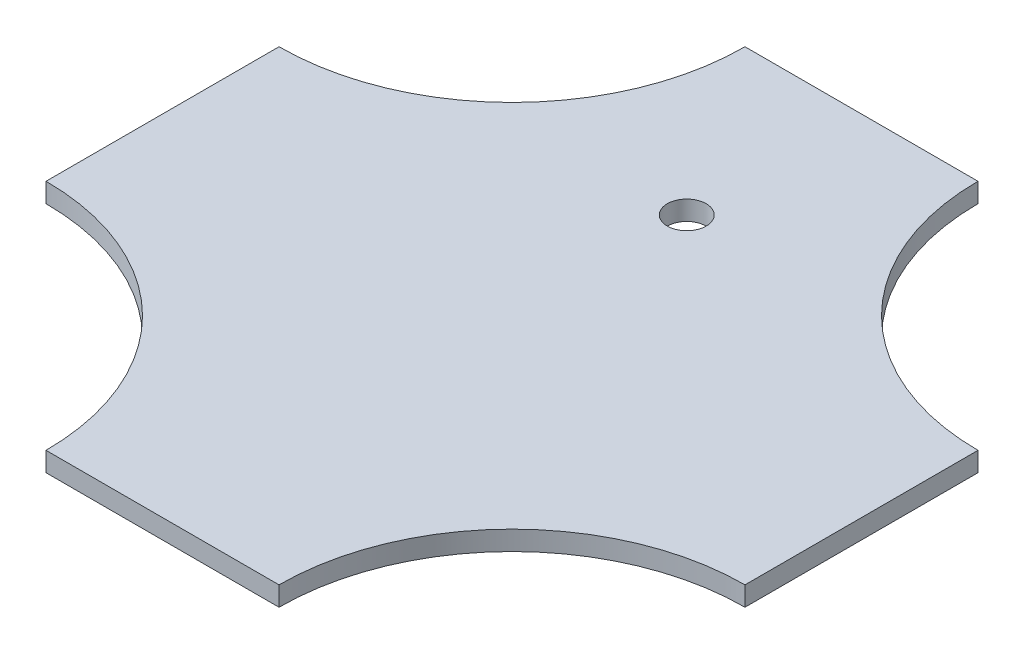
from build123d import *

# Parameters (mm, degrees)
BOSS_EXTRUDE1_DEPTH = 10
SKETCH2_R           = 10
CUT_EXTRUDE1_DEPTH  = 10
CUT_EXTRUDE3_DEPTH  = 4


with BuildPart() as part:
    # Sketch1 → Boss-Extrude1 (new body)
    with BuildSketch(Plane(origin=(0, 0, 0), x_dir=(1, 0, 0), z_dir=(0, 1, 0))):
        Polygon((60, -60), (60, -180), (-60, -180), (-60, -60), (-180, -60), (-180, 60), (-60, 60), (-60, 180), (60, 180), (60, 60), (180, 60), (180, -60), align=None)
        with BuildLine():
            Line((-60, 180), (-60, 60))
            Line((-60, 60), (-180, 60))
            ThreePointArc((-180, 60), (-95.147186258, 95.147186258), (-60, 180))
        make_face()
        with BuildLine():
            ThreePointArc((60, 180), (95.147186258, 95.147186258), (180, 60))
            Line((180, 60), (60, 60))
            Line((60, 60), (60, 180))
        make_face()
        with BuildLine():
            ThreePointArc((180, -60), (95.147186258, -95.147186258), (60, -180))
            Line((60, -180), (60, -60))
            Line((60, -60), (180, -60))
        make_face()
        with BuildLine():
            Line((-180, -60), (-60, -60))
            Line((-60, -60), (-60, -180))
            ThreePointArc((-60, -180), (-95.147186258, -95.147186258), (-180, -60))
        make_face()
    extrude(amount=BOSS_EXTRUDE1_DEPTH)

    # Sketch2 → Cut-Extrude1 (cut)
    with BuildSketch(Plane.XZ):
        with Locations((0, -90)):
            Circle(SKETCH2_R)
    extrude(amount=-CUT_EXTRUDE1_DEPTH, mode=Mode.SUBTRACT)

    # Sketch5 → Cut-Extrude3 (cut)
    with BuildSketch(Plane.XZ):
        Polygon((24.5, -110), (-24.5, -110), (-28.5, -110), (-28.5, -114), (28.5, -114), (28.5, -110), align=None)
    extrude(amount=-CUT_EXTRUDE3_DEPTH, mode=Mode.SUBTRACT)


solid = part.part
